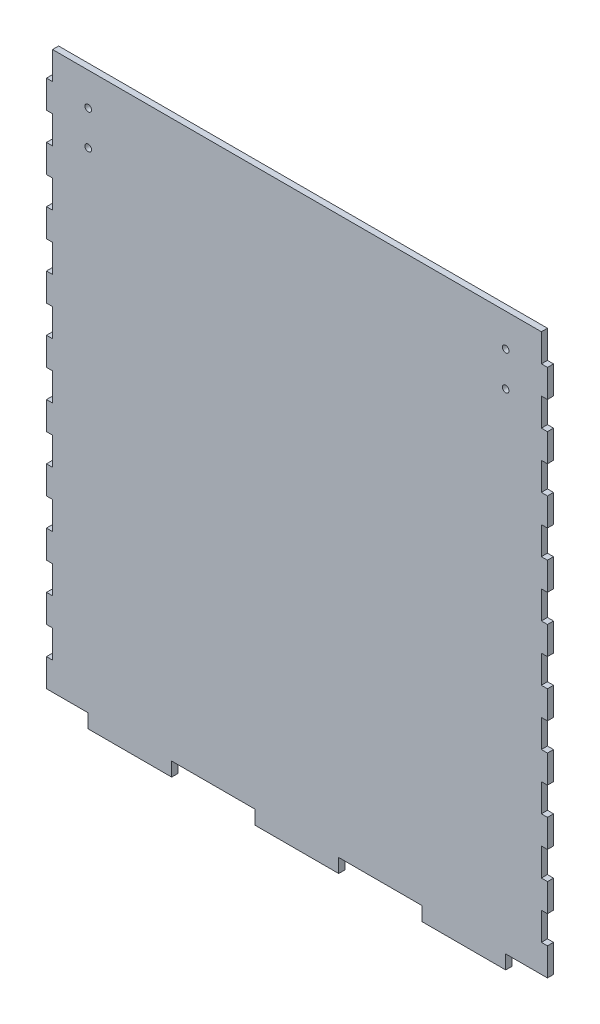
from build123d import *

# Parameters (mm, degrees)
BOSS_EXTRUDE1_DEPTH = 2.778125
SKETCH3_R           = 1.5
SKETCH3_R_2         = 1.499997
CUT_EXTRUDE2_DEPTH  = 2.778125


with BuildPart() as part:
    # Sketch1 → Boss-Extrude1 (new body)
    with BuildSketch(Plane.XY):
        Polygon((-111.521875, 114.3), (-114.3, 114.3), (-114.3, 101.6), (-111.521875, 101.6), (-111.521875, 88.9), (-114.3, 88.9), (-114.3, 76.2), (-111.521875, 76.2), (-111.521875, 63.5), (-114.3, 63.5), (-114.3, 50.8), (-111.521875, 50.8), (-111.521875, 38.1), (-114.3, 38.1), (-114.3, 25.4), (-111.521875, 25.4), (-111.521875, 12.7), (-114.3, 12.7), (-114.3, 0), (-111.521875, 0), (-111.521875, -12.7), (-114.3, -12.7), (-114.3, -25.4), (-111.521875, -25.4), (-111.521875, -38.1), (-114.3, -38.1), (-114.3, -50.8), (-111.521875, -50.8), (-111.521875, -63.5), (-114.3, -63.5), (-114.3, -76.2), (-111.521875, -76.2), (-111.521875, -88.9), (-114.3, -88.9), (-114.3, -101.6), (-111.521875, -101.6), (-111.521875, -114.3), (-114.3, -114.3), (-114.3, -127), (-95.25, -127), (-95.25, -133.35), (-57.15, -133.35), (-57.15, -127), (-19.05, -127), (-19.05, -133.35), (19.05, -133.35), (19.05, -127), (57.15, -127), (57.15, -133.35), (95.25, -133.35), (95.25, -127), (114.3, -127), (114.3, -114.3), (111.521875, -114.3), (111.521875, -101.6), (114.3, -101.6), (114.3, -88.9), (111.521875, -88.9), (111.521875, -76.2), (114.3, -76.2), (114.3, -63.5), (111.521875, -63.5), (111.521875, -50.8), (114.3, -50.8), (114.3, -38.1), (111.521875, -38.1), (111.521875, -25.4), (114.3, -25.4), (114.3, -12.7), (111.521875, -12.7), (111.521875, 0), (114.3, 0), (114.3, 12.7), (111.521875, 12.7), (111.521875, 25.4), (114.3, 25.4), (114.3, 38.1), (111.521875, 38.1), (111.521875, 50.8), (114.3, 50.8), (114.3, 63.5), (111.521875, 63.5), (111.521875, 76.2), (114.3, 76.2), (114.3, 88.9), (111.521875, 88.9), (111.521875, 101.6), (114.3, 101.6), (114.3, 114.3), (111.521875, 114.3), (111.521875, 127), (-111.521875, 127), align=None)
    extrude(amount=BOSS_EXTRUDE1_DEPTH)

    # Sketch3 → Cut-Extrude2 (cut)
    with BuildSketch(Plane(origin=(0, 0, 0), x_dir=(-1, 0, 0), z_dir=(0, 0, -1))):
        with Locations((-95.25, 112)):
            Circle(SKETCH3_R)
        with Locations((-95.25, 96.25)):
            Circle(SKETCH3_R_2)
        with Locations((95.25, 96.25)):
            Circle(SKETCH3_R_2)
        with Locations((95.25, 112)):
            Circle(SKETCH3_R)
    extrude(amount=-CUT_EXTRUDE2_DEPTH, mode=Mode.SUBTRACT)


solid = part.part
